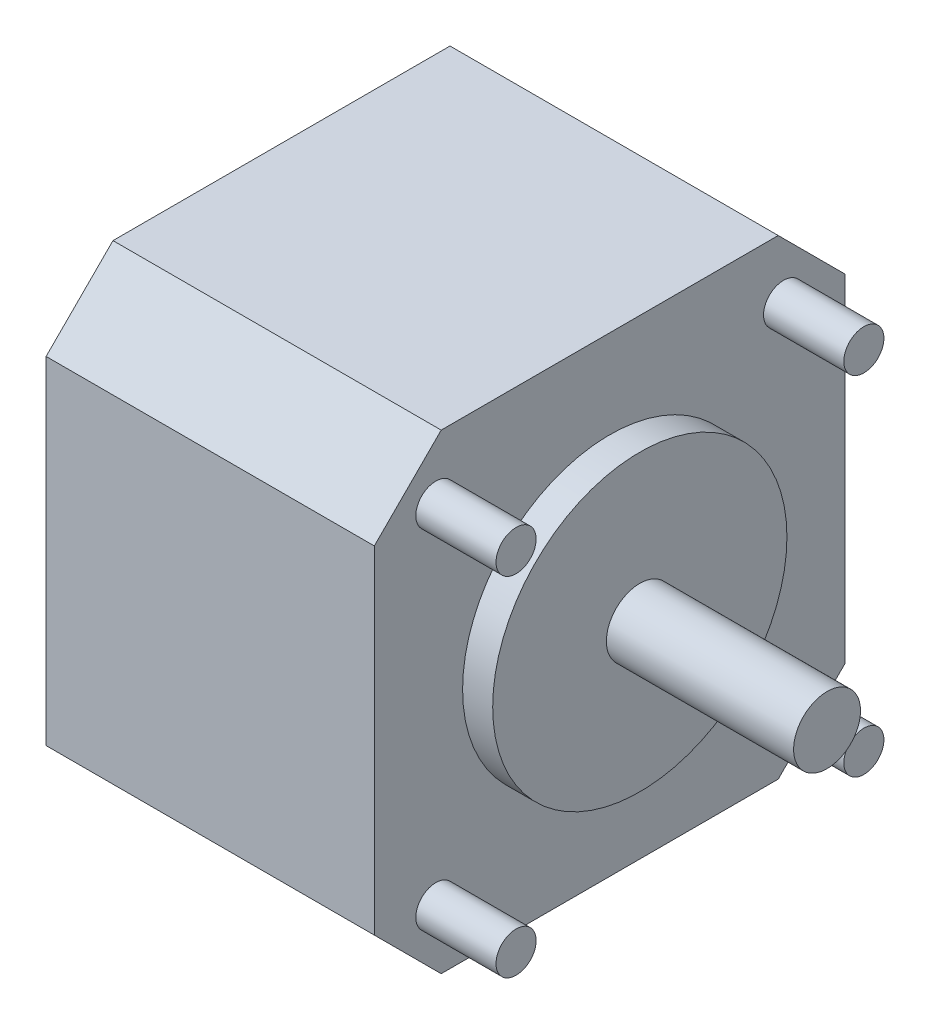
from build123d import *

# Parameters (mm, degrees)
SKETCH1_W           = 24.54
SKETCH1_H           = 35.2
MAIN_BODY_DEPTH     = 35.2
SKETCH2_R           = 11
LIP_DEPTH           = 2.25
SKETCH3_R           = 2.5
SHAFT_DEPTH         = 14
CHAMFER1_SIZE       = 5
SKETCH4_R           = 1.5
BOSS_EXTRUDE4_DEPTH = 6


with BuildPart() as part:
    # Sketch1 → Main body (new body)
    with BuildSketch(Plane(origin=(0, 0, 0), x_dir=(1, 0, 0), z_dir=(0, 1, 0))):
        with Locations((12.27, 17.6)):
            Rectangle(SKETCH1_W, SKETCH1_H)
    extrude(amount=MAIN_BODY_DEPTH)

    # Sketch2 → lip (add)
    with BuildSketch(Plane(origin=(24.54, 0, 0), x_dir=(0, 0, -1), z_dir=(1, 0, 0))):
        with Locations((17.6, 17.6)):
            Circle(SKETCH2_R)
    extrude(amount=LIP_DEPTH)

    # Sketch3 → shaft (add)
    with BuildSketch(Plane(origin=(26.79, 0, 0), x_dir=(0, 0, -1), z_dir=(1, 0, 0))):
        with Locations((17.6, 17.6)):
            Circle(SKETCH3_R)
    extrude(amount=SHAFT_DEPTH)

    # Chamfer1
    chamfer1_edges = [part.edges().sort_by_distance(p)[0] for p in [
        (12.27, 35.2, -35.2),
        (12.27, 0, -35.2),
        (12.27, 0, 0),
        (12.27, 35.2, 0),
    ]]
    chamfer(chamfer1_edges, length=CHAMFER1_SIZE)

    # Sketch4 → Boss-Extrude4 (add)
    with BuildSketch(Plane(origin=(24.54, 0, 0), x_dir=(0, 0, -1), z_dir=(1, 0, 0))):
        with Locations((30.6, 30.6)):
            Circle(SKETCH4_R)
        with Locations((30.6, 4.6)):
            Circle(SKETCH4_R)
        with Locations((4.6, 30.6)):
            Circle(SKETCH4_R)
        with Locations((4.6, 4.6)):
            Circle(SKETCH4_R)
    extrude(amount=BOSS_EXTRUDE4_DEPTH)


solid = part.part
